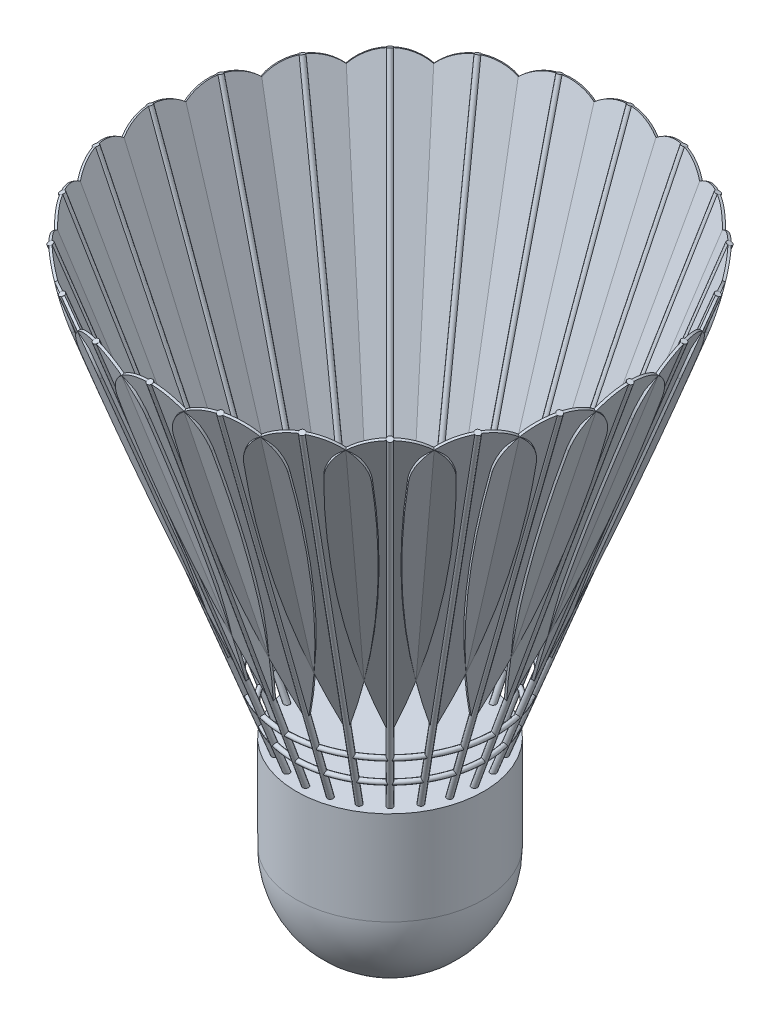
from build123d import *

# Parameters (mm, degrees)
SKETCH6_W           = 50
SKETCH6_H           = 0.3
BOSS_EXTRUDE1_DEPTH = 0.13
CIRPATTERN2_COUNT   = 24
SKETCH14_R          = 0.25


with BuildPart() as part:
    # Sketch2 → Revolve1 (revolve)
    with BuildSketch(Plane.XY):
        with BuildLine():
            Line((0, 0), (0, -20))
            ThreePointArc((0, -20), (7.071067812, -17.071067812), (10, -10))
            Line((10, -10), (10, 0))
            Line((10, 0), (0, 0))
        make_face()
    revolve(axis=Axis((0, 0, 0), (0, -1, 0)))

    # Sketch6 → Revolve2 (revolve)
    with BuildSketch(Plane(origin=(7.947199994, -2.892544244, 0), x_dir=(-0.34202014332565944, -0.9396926207859118, 0), z_dir=(0.9396926207859118, -0.34202014332565944, 0))):
        with Locations((-26.710100717, 0.15)):
            Rectangle(SKETCH6_W, SKETCH6_H)
    revolve2 = revolve(axis=Axis((8.532088886, -1.285575219, 0), (0.34202014332565955, 0.9396926207859118, 0)))

    # Sketch7 → Boss-Extrude1 (add, symmetric)
    with BuildSketch(Plane(origin=(7.947199994, -2.892544244, 0), x_dir=(-0.34202014332565944, -0.9396926207859118, 0), z_dir=(0.9396926207859118, -0.34202014332565944, 0))):
        with BuildLine():
            ThreePointArc((-46.710100717, -5), (-51.710100717, 0), (-46.710100717, 5))
            add(Edge.make_bspline(
                [(-46.710100717, 5), (-28.727872307, 5), (-12.710100717, 0)],
                knots=[0, 0, 0, 1, 1, 1], degree=2))
            add(Edge.make_bspline(
                [(-46.710100717, -5), (-28.727872307, -5), (-12.710100717, 0)],
                knots=[0, 0, 0, 1, 1, 1], degree=2))
        make_face()
    boss_extrude1 = extrude(amount=BOSS_EXTRUDE1_DEPTH, both=True)

    # CirPattern2: Revolve2, Boss-Extrude1 ×24 about axis
    cirpattern2_axis = Axis((0, 0, 0), (0, 1, 0))
    add([revolve2.rotate(cirpattern2_axis, i * 360 / CIRPATTERN2_COUNT) for i in range(1, CIRPATTERN2_COUNT)])
    add([boss_extrude1.rotate(cirpattern2_axis, i * 360 / CIRPATTERN2_COUNT) for i in range(1, CIRPATTERN2_COUNT)])

    # Sketch14 → Revolve3 (revolve)
    with BuildSketch(Plane.YX):
        with Locations((6.009212818, 11.187174597)):
            Circle(SKETCH14_R)
        with Locations((3.009212818, 10.095263894)):
            Circle(SKETCH14_R)
    revolve(axis=Axis((0, 0, 0), (0, 1, 0)))


solid = part.part
